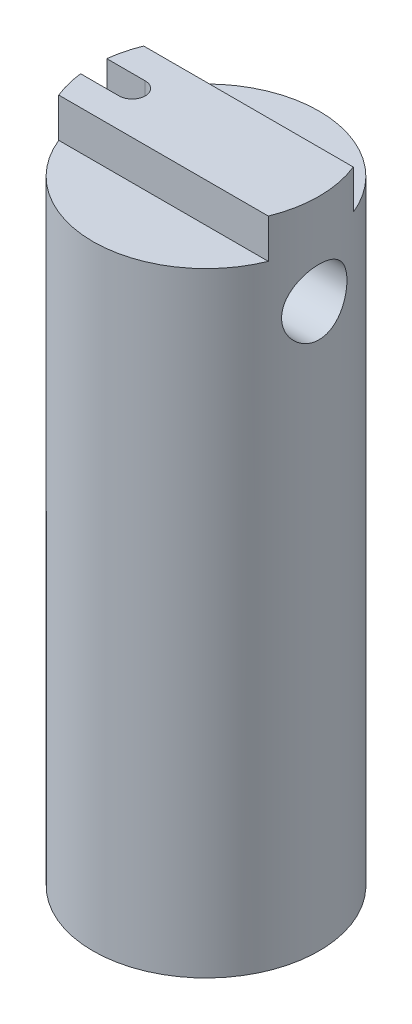
from build123d import *

# Parameters (mm, degrees)
SKETCH_1_R               = 8.65
EXTRUDE_1_DEPTH          = 50
CUT_EXTRUDE_1_DEPTH      = 40
CUT_EXTRUDE_2_DEPTH      = 51
SKETCH_4_W               = 7.4
SKETCH_4_H               = 3
CUT_EXTRUDE_3_DEPTH      = 9.65
CUT_EXTRUDE_3_DEPTH_BACK = 9.592002095
HOLE_WIZARD_M61_D        = 5
HOLE_WIZARD_M61_DEPTH    = 5
HOLE_WIZARD_M61_TIP      = 1.502151548


with BuildPart() as part:
    # Эскиз1 → Бобышка-Вытянуть1 (new body)
    with BuildSketch(Plane(origin=(0, 0, 0), x_dir=(1, 0, 0), z_dir=(0, 1, 0))):
        Circle(SKETCH_1_R)
    extrude(amount=-EXTRUDE_1_DEPTH)

    # Эскиз2 → Вырез-Вытянуть1 (cut)
    with BuildSketch(Plane.XZ.offset(50)):
        with BuildLine():
            Line((-5.65, -3), (-8.65, -3))
            ThreePointArc((-8.65, -3), (-11.65, 0), (-8.65, 3))
            Line((-8.65, 3), (-5.65, 3))
            ThreePointArc((-5.65, 3), (-2.65, 0), (-5.65, -3))
        make_face()
    extrude(amount=-CUT_EXTRUDE_1_DEPTH, mode=Mode.SUBTRACT)

    # Эскиз3 → Вырез-Вытянуть2 (cut, through all)
    with BuildSketch(Plane.XZ):
        with BuildLine():
            Line((-5.65, -1), (-8.65, -1))
            ThreePointArc((-8.65, -1), (-9.65, 0), (-8.65, 1))
            Line((-8.65, 1), (-5.65, 1))
            ThreePointArc((-5.65, 1), (-4.65, 0), (-5.65, -1))
        make_face()
    extrude(amount=CUT_EXTRUDE_2_DEPTH, mode=Mode.SUBTRACT)

    # Эскиз4 → Вырез-Вытянуть3 (cut, two sides)
    with BuildSketch(Plane(origin=(0, 0, 0), x_dir=(0, 0, -1), z_dir=(1, 0, 0))) as cut_extrude_3_sk:
        with Locations((6.95, -1.5)):
            Rectangle(SKETCH_4_W, SKETCH_4_H)
        with Locations((-6.95, -1.5)):
            Rectangle(SKETCH_4_W, SKETCH_4_H)
    extrude(amount=CUT_EXTRUDE_3_DEPTH, mode=Mode.SUBTRACT)
    extrude(cut_extrude_3_sk.sketch, amount=-CUT_EXTRUDE_3_DEPTH_BACK, mode=Mode.SUBTRACT)

    # Отверстие обработанное метчиком M61
    with Locations(Plane(origin=(8.65, 0, 0), x_dir=(0, 0, -1), z_dir=(1, 0, 0))):
        with Locations((0, -7)):
            Hole(HOLE_WIZARD_M61_D / 2, depth=HOLE_WIZARD_M61_DEPTH)
            with Locations((0, 0, -(HOLE_WIZARD_M61_DEPTH + HOLE_WIZARD_M61_TIP / 2))):  # 118° drill point
                Cone(0, HOLE_WIZARD_M61_D / 2, HOLE_WIZARD_M61_TIP, mode=Mode.SUBTRACT)


solid = part.part
